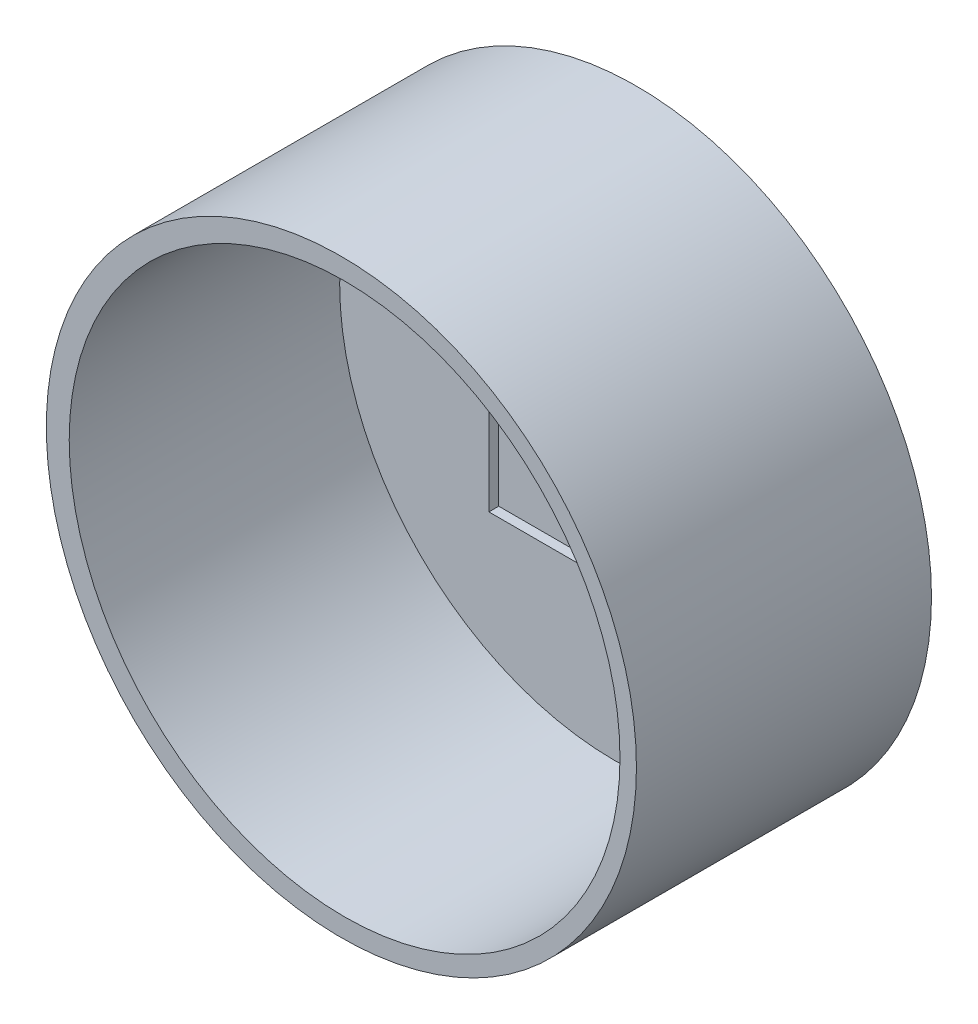
from build123d import *

# Parameters (mm, degrees)
SKETCH1_R           = 76.2
SKETCH1_R_2         = 71.12
BOSS_EXTRUDE1_DEPTH = 76.2
SKETCH3_R           = 76.2
BOSS_EXTRUDE2_DEPTH = 6.35
SKETCH4_W           = 63.5
SKETCH4_H           = 63.5
CUT_EXTRUDE1_DEPTH  = 2.54


with BuildPart() as part:
    # Sketch1 → Boss-Extrude1 (new body)
    with BuildSketch(Plane.XY):
        Circle(SKETCH1_R)
        with Locations((0.828825483, 0)):
            Circle(SKETCH1_R_2, mode=Mode.SUBTRACT)
    extrude(amount=BOSS_EXTRUDE1_DEPTH)

    # Sketch3 → Boss-Extrude2 (add)
    with BuildSketch(Plane.XY):
        Circle(SKETCH3_R)
    extrude(amount=BOSS_EXTRUDE2_DEPTH)

    # Sketch4 → Cut-Extrude1 (cut)
    with BuildSketch(Plane.XY.offset(6.35)):
        Rectangle(SKETCH4_W, SKETCH4_H)
    extrude(amount=-CUT_EXTRUDE1_DEPTH, mode=Mode.SUBTRACT)


solid = part.part
